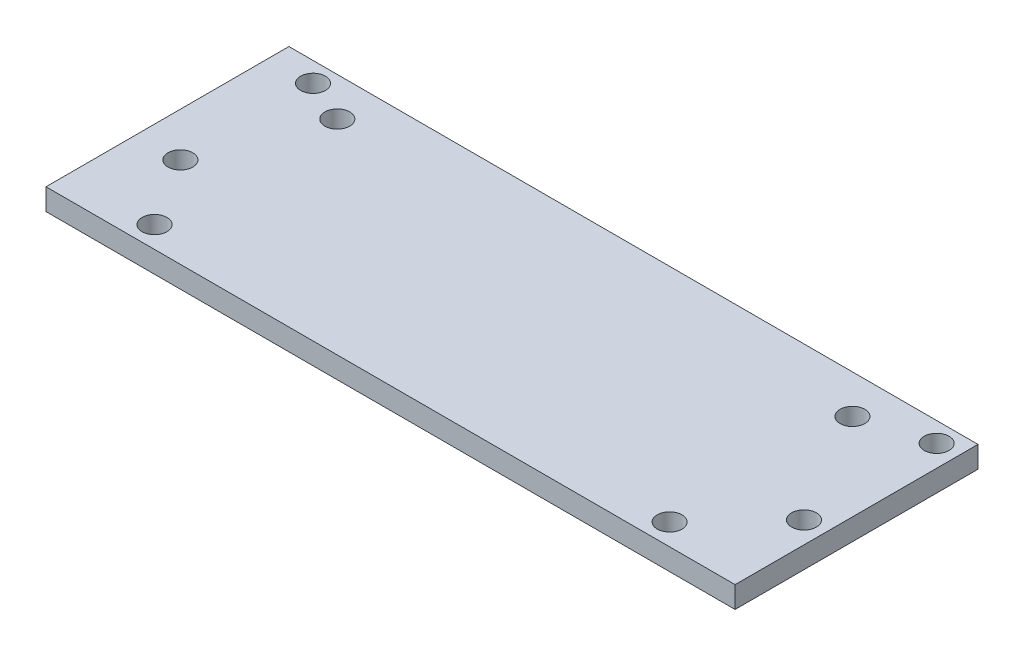
from build123d import *

# Parameters (mm, degrees)
SKETCH2_W           = 101.6
SKETCH2_H           = 35.814
BOSS_EXTRUDE1_DEPTH = 3.175
SKETCH3_R           = 1.8288
CUT_EXTRUDE1_DEPTH  = 4.175
SKETCH4_R           = 1.8288
CUT_EXTRUDE2_DEPTH  = 4.175


with BuildPart() as part:
    # Sketch2 → Boss-Extrude1 (new body)
    with BuildSketch(Plane(origin=(0, 0, 0), x_dir=(1, 0, 0), z_dir=(0, 1, 0))):
        Rectangle(SKETCH2_W, SKETCH2_H)
    extrude(amount=BOSS_EXTRUDE1_DEPTH)

    # Sketch3 → Cut-Extrude1 (cut, through all)
    with BuildSketch(Plane(origin=(0, 3.175, 0), x_dir=(1, 0, 0), z_dir=(0, 1, 0))):
        with Locations((47.625, 14.986)):
            Circle(SKETCH3_R)
        with Locations((47.625, -4.572)):
            Circle(SKETCH3_R)
        with Locations((-44.323, 14.986)):
            Circle(SKETCH3_R)
        with Locations((-44.323, -4.572)):
            Circle(SKETCH3_R)
    extrude(amount=-CUT_EXTRUDE1_DEPTH, mode=Mode.SUBTRACT)

    # Sketch4 → Cut-Extrude2 (cut, through all)
    with BuildSketch(Plane(origin=(0, 3.175, 0), x_dir=(1, 0, 0), z_dir=(0, 1, 0))):
        with Locations((-37.973, -14.732)):
            Circle(SKETCH4_R)
        with Locations((-37.973, 12.2174)):
            Circle(SKETCH4_R)
        with Locations((37.973, -14.732)):
            Circle(SKETCH4_R)
        with Locations((37.973, 12.2174)):
            Circle(SKETCH4_R)
    extrude(amount=-CUT_EXTRUDE2_DEPTH, mode=Mode.SUBTRACT)


solid = part.part
